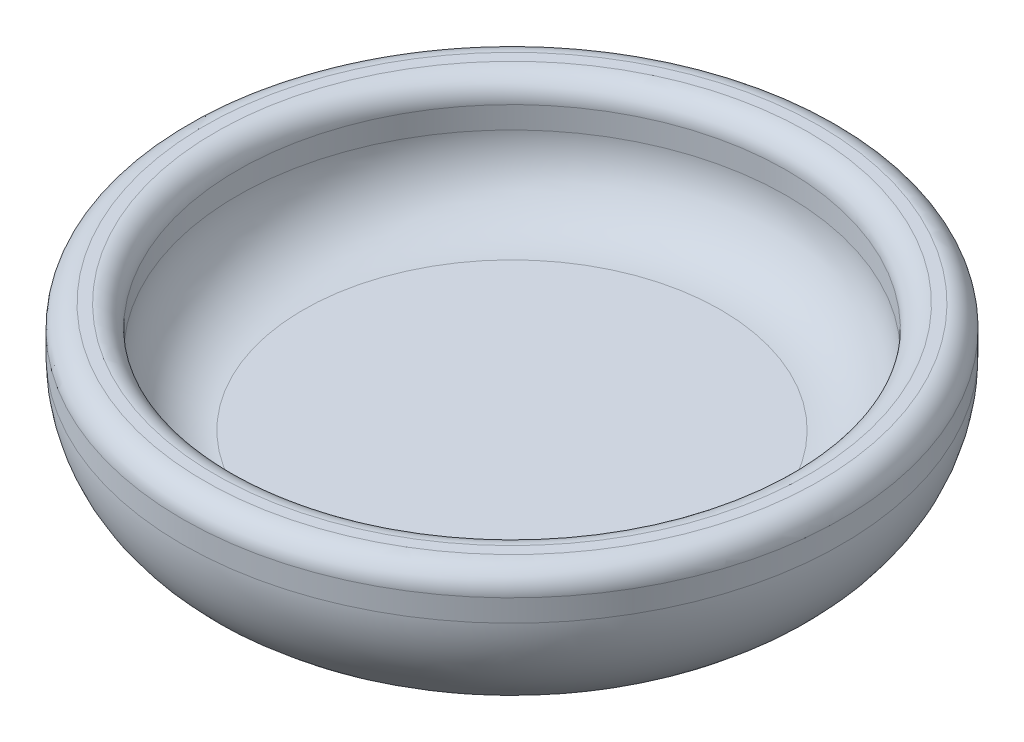
from build123d import *


with BuildPart() as part:
    # Sketch1 → Revolve1 (revolve)
    with BuildSketch(Plane.XY):
        with BuildLine():
            Line((0, 0), (0, 6.35))
            Line((0, 6.35), (24.13, 6.35))
            ThreePointArc((24.13, 6.35), (29.518153673, 8.581846327), (31.75, 13.97))
            Line((31.75, 13.97), (31.75, 16.51))
            ThreePointArc((31.75, 16.51), (32.493948776, 18.306051224), (34.29, 19.05))
            Line((34.29, 19.05), (35.56, 19.05))
            ThreePointArc((35.56, 19.05), (37.356051224, 18.306051224), (38.1, 16.51))
            Line((38.1, 16.51), (38.1, 13.97))
            ThreePointArc((38.1, 13.97), (34.008281733, 4.091718267), (24.13, 0))
            Line((24.13, 0), (0, 0))
        make_face()
    revolve(axis=Axis((0, 0, 0), (0, 1, 0)))


solid = part.part
